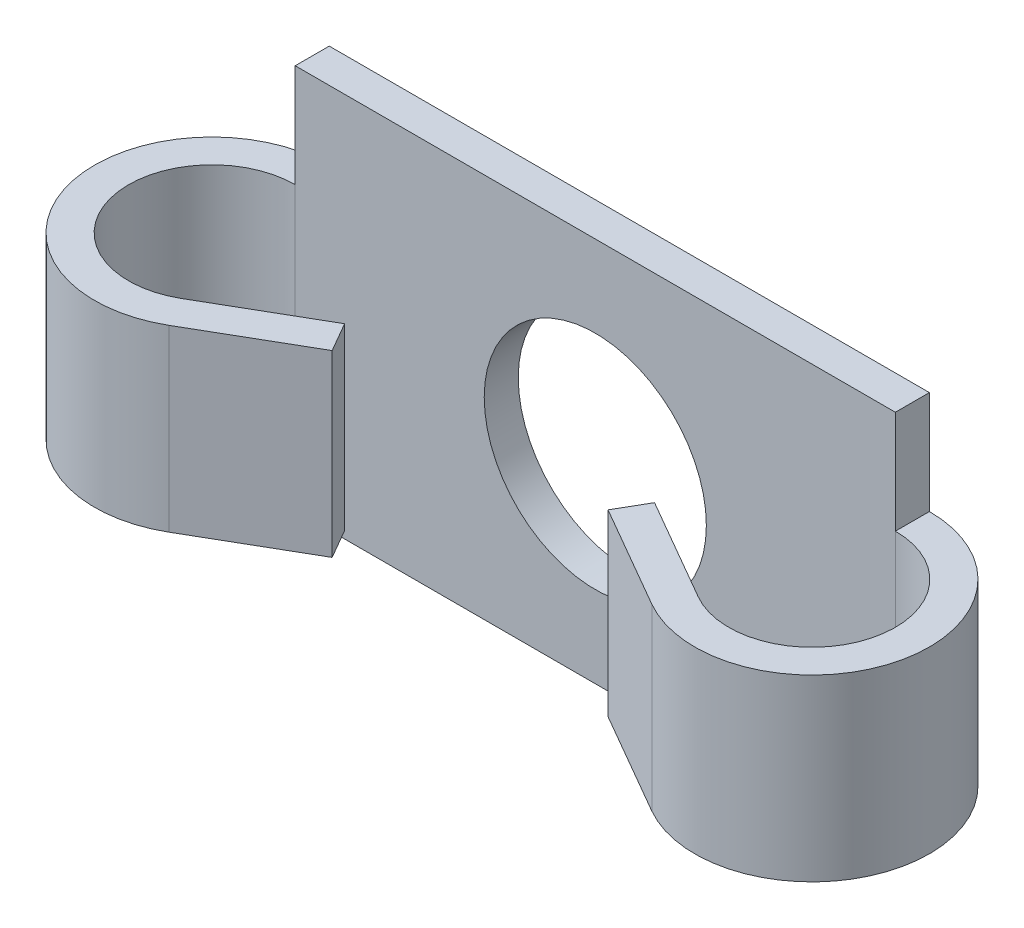
from build123d import *

# Parameters (mm, degrees)
SKETCH_1_W      = 33.5
SKETCH_1_H      = 21.5
SKETCH_1_R      = 6.2
EXTRUDE_1_DEPTH = 1.9
EXTRUDE_2_DEPTH = 5


with BuildPart() as part:
    # Эскиз1 → Бобышка-Вытянуть1 (new body)
    with BuildSketch(Plane.XY):
        Rectangle(SKETCH_1_W, SKETCH_1_H)
        Circle(SKETCH_1_R, mode=Mode.SUBTRACT)
    extrude(amount=EXTRUDE_1_DEPTH)

    # Эскиз3 → Бобышка-Вытянуть2 (add, symmetric)
    with BuildSketch(Plane(origin=(0, 0, 0), x_dir=(1, 0, 0), z_dir=(0, 1, 0))):
        with BuildLine():
            Line((-14.425, -10.577018128), (-8.65, -7.242820323))
            Line((-8.65, -7.242820323), (-7.7, -8.88826859))
            Line((-7.7, -8.88826859), (-13.475, -12.222466395))
            ThreePointArc((-13.475, -12.222466395), (-23.076814162, -8.245264745), (-16.75, 0))
            Line((-16.75, 0), (-16.75, -1.9))
            ThreePointArc((-16.75, -1.9), (-21.241555092, -7.75350856), (-14.425, -10.577018128))
        make_face()
    extrude_2 = extrude(amount=EXTRUDE_2_DEPTH, both=True)

    # Зеркальное отражение1: Бобышка-Вытянуть2 across plane
    add(extrude_2.mirror(Plane(origin=(0, 0, 0), x_dir=(0, 0, 1), z_dir=(1, 0, 0))))


solid = part.part
